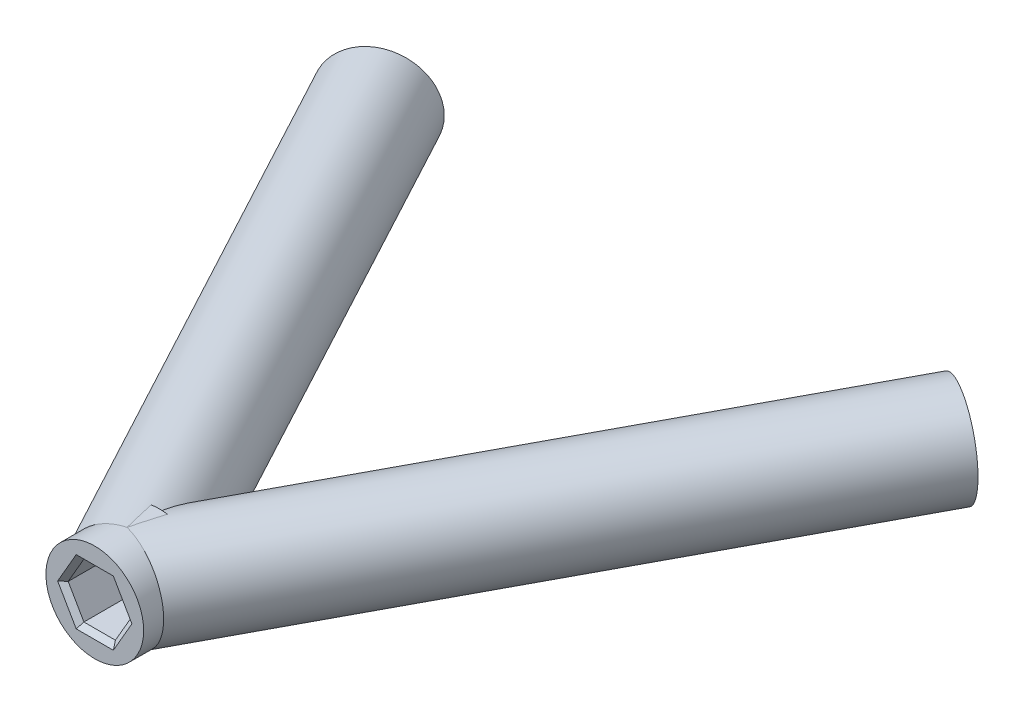
from build123d import *

# Parameters (mm, degrees)
SKETCH1_W           = 5
SKETCH1_H           = 6.6
BOSS_EXTRUDE1_REACH = 70.079
SKETCH3_R           = 5
BOSS_EXTRUDE2_REACH = 83.814
SKETCH4_R           = 5
CUT_EXTRUDE1_DEPTH  = 6.6
CUT_EXTRUDE2_DEPTH  = 6.6
CUT_EXTRUDE3_DEPTH  = 6.6
CHAMFER1_SIZE       = 0.5


with BuildPart() as part:
    # Sketch1 → Revolve-Thin2 (revolve)
    with BuildSketch(Plane(origin=(0, 0, 0), x_dir=(1, 0, 0), z_dir=(0, 1, 0))):
        with Locations((-2.5, 20.8)):
            Rectangle(SKETCH1_W, SKETCH1_H)
    revolve(axis=Axis((0, 0, -17.5), (0, 0, -1)))

    # Sketch3 → Boss-Extrude1 (add, up to next)
    with BuildSketch(Plane(origin=(-38.328954944, 0, -71.518501264), x_dir=(0.881400586, 0, -0.472369565), z_dir=(0.472369565, 0, 0.881400586)), mode=Mode.PRIVATE) as boss_extrude1_sk1:
        with Locations((9.825286961, 0)):
            Circle(SKETCH3_R)
    boss_extrude1_tool1 = extrude(boss_extrude1_sk1.sketch, amount=BOSS_EXTRUDE1_REACH, mode=Mode.PRIVATE) - part.part
    add(boss_extrude1_tool1.solids().sort_by_distance((-29.668941, 0, -76.159668))[0])

    # Sketch4 → Boss-Extrude2 (add, up to next)
    with BuildSketch(Plane(origin=(38.328954944, 0, -71.518501264), x_dir=(0.881400586, 0, 0.472369565), z_dir=(-0.472369565, 0, 0.881400586)), mode=Mode.PRIVATE) as boss_extrude2_sk1:
        with Locations((-9.825286961, 0)):
            Circle(SKETCH4_R)
    boss_extrude2_tool1 = extrude(boss_extrude2_sk1.sketch, amount=BOSS_EXTRUDE2_REACH, mode=Mode.PRIVATE) - part.part
    add(boss_extrude2_tool1.solids().sort_by_distance((29.668941, 0, -76.159668))[0])

    # Sketch5 → Cut-Extrude1 (cut)
    with BuildSketch(Plane.XY.offset(-17.5)):
        Polygon((1.610807251, 2.79), (-1.610807251, 2.79), (-3.221614502, 0), (-1.610807251, -2.79), (1.610807251, -2.79), (3.221614502, 0), align=None)
    extrude(amount=-CUT_EXTRUDE1_DEPTH, mode=Mode.SUBTRACT)

    # Sketch7 → Cut-Extrude2 (cut)
    with BuildSketch(Plane(origin=(-38.328954944, 0, -71.518501264), x_dir=(-0.881400586, 0, 0.472369565), z_dir=(-0.472369565, 0, -0.881400586))):
        Polygon((-7.035286961, 1.610807251), (-9.825286961, 3.221614502), (-12.615286961, 1.610807251), (-12.615286961, -1.610807251), (-9.825286961, -3.221614502), (-7.035286961, -1.610807251), align=None)
    extrude(amount=-CUT_EXTRUDE2_DEPTH, mode=Mode.SUBTRACT)

    # Sketch8 → Cut-Extrude3 (cut)
    with BuildSketch(Plane(origin=(38.328954944, 0, -71.518501264), x_dir=(-0.881400586, 0, -0.472369565), z_dir=(0.472369565, 0, -0.881400586))):
        Polygon((12.615286961, 1.610807251), (9.825286961, 3.221614502), (7.035286961, 1.610807251), (7.035286961, -1.610807251), (9.825286961, -3.221614502), (12.615286961, -1.610807251), align=None)
    extrude(amount=-CUT_EXTRUDE3_DEPTH, mode=Mode.SUBTRACT)

    # Chamfer1
    chamfer1_edges = [part.edges().sort_by_distance(p)[0] for p in [
        (2.416210877, 1.395, -17.5),
        (0, 2.79, -17.5),
        (-2.416210877, 1.395, -17.5),
        (-2.416210877, -1.395, -17.5),
        (0, -2.79, -17.5),
        (2.416210877, -1.395, -17.5),
        (-32.128048891, 0, -74.841756709),
        (-30.898495073, 2.416210877, -75.500712253),
        (-28.439387437, 2.416210877, -76.81862334),
        (-27.209833619, 0, -77.477578884),
        (-28.439387437, -2.416210877, -76.81862334),
        (-30.898495073, -2.416210877, -75.500712253),
        (27.209833619, 0, -77.477578884),
        (28.439387437, 2.416210877, -76.81862334),
        (30.898495073, 2.416210877, -75.500712253),
        (32.128048891, 0, -74.841756709),
        (30.898495073, -2.416210877, -75.500712253),
        (28.439387437, -2.416210877, -76.81862334),
    ]]
    chamfer(chamfer1_edges, length=CHAMFER1_SIZE)


solid = part.part
